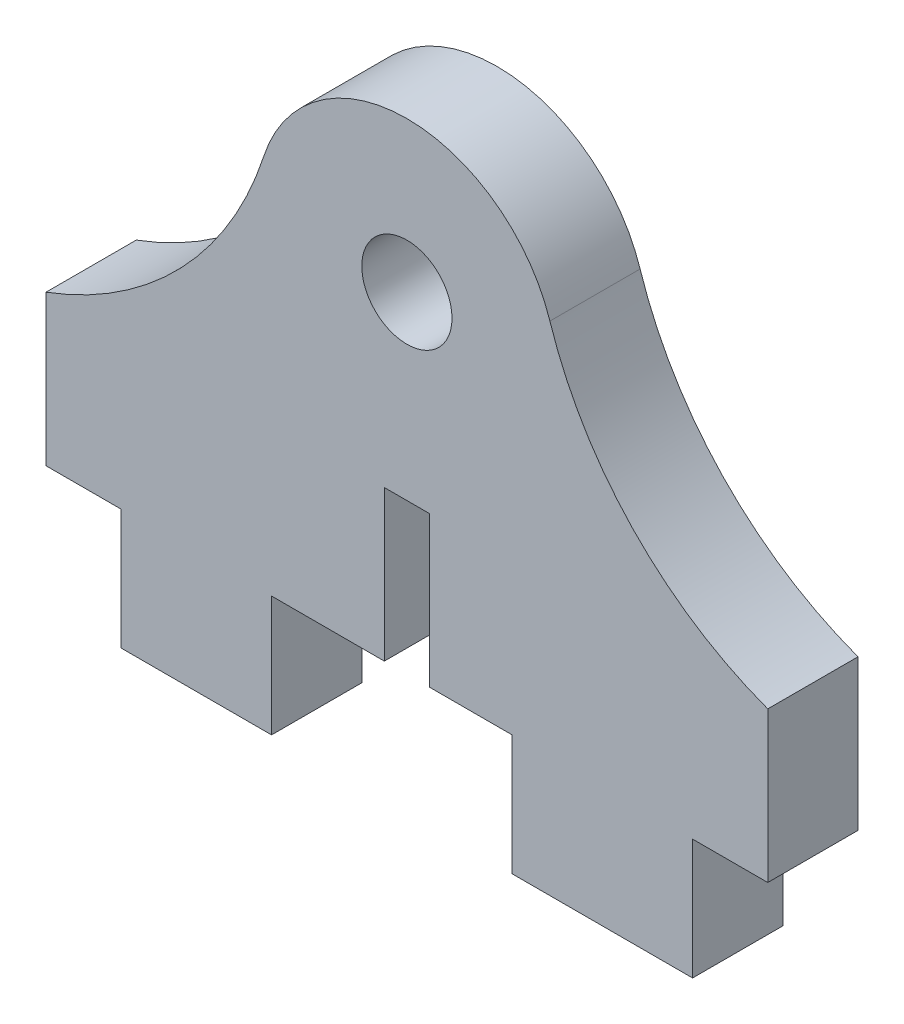
from build123d import *

# Parameters (mm, degrees)
SKETCH1_R           = 1.5
SKETCH1_R_2         = 1
BOSS_EXTRUDE1_DEPTH = 3
SKETCH2_W           = 21.215315346
SKETCH2_H           = 10.620784377
CUT_EXTRUDE1_DEPTH  = 4
SKETCH3_W           = 2.5
SKETCH3_H           = 4
CUT_EXTRUDE2_DEPTH  = 10
SKETCH4_W           = 2.5
SKETCH4_H           = 4
BOSS_EXTRUDE2_DEPTH = 3
SKETCH5_W           = 2.5
SKETCH5_H           = 5.5
BOSS_EXTRUDE3_DEPTH = 3
SKETCH6_W           = 1.5
SKETCH6_H           = 10
CUT_EXTRUDE3_DEPTH  = 5


with BuildPart() as part:
    # Sketch1 → Boss-Extrude1 (new body)
    with BuildSketch(Plane.XY):
        with BuildLine():
            Line((-1.25, -11), (-7, -11))
            Line((-7, -11), (-7, -15))
            Line((-7, -15), (-12, -15))
            Line((-12, -15), (-12, -11))
            Line((-12, -11), (-12, -6))
            ThreePointArc((-12, -6), (-7.512319363, -3.05842228), (-4.755323166, 1.544960058))
            ThreePointArc((-4.755323166, 1.544960058), (0, 5), (4.755323166, 1.544960058))
            ThreePointArc((4.755323166, 1.544960058), (7.512319363, -3.05842228), (12, -6))
            Line((12, -6), (12, -22.5))
            ThreePointArc((12, -22.5), (11.267766953, -24.267766953), (9.5, -25))
            Line((9.5, -25), (8.5, -25))
            ThreePointArc((8.5, -25), (6.732233047, -24.267766953), (6, -22.5))
            Line((6, -22.5), (6, -11))
            Line((6, -11), (1.25, -11))
            Line((1.25, -11), (1.25, -5.5))
            Line((1.25, -5.5), (-1.25, -5.5))
            Line((-1.25, -5.5), (-1.25, -11))
        make_face()
        Circle(SKETCH1_R, mode=Mode.SUBTRACT)
        with Locations((9, -22)):
            Circle(SKETCH1_R_2, mode=Mode.SUBTRACT)
    extrude(amount=BOSS_EXTRUDE1_DEPTH)

    # Sketch2 → Cut-Extrude1 (cut, through all)
    with BuildSketch(Plane.XY.offset(3)):
        with Locations((3.607657673, -20.310392189)):
            Rectangle(SKETCH2_W, SKETCH2_H)
    extrude(amount=-CUT_EXTRUDE1_DEPTH, mode=Mode.SUBTRACT)

    # Sketch3 → Cut-Extrude2 (cut)
    with BuildSketch(Plane.XY.offset(3)):
        with Locations((10.75, -13)):
            Rectangle(SKETCH3_W, SKETCH3_H)
        with Locations((-10.75, -13)):
            Rectangle(SKETCH3_W, SKETCH3_H)
    extrude(amount=-CUT_EXTRUDE2_DEPTH, mode=Mode.SUBTRACT)

    # Sketch4 → Boss-Extrude2 (add)
    with BuildSketch(Plane.XY.offset(3)):
        with Locations((-5.75, -13)):
            Rectangle(SKETCH4_W, SKETCH4_H)
        with Locations((4.75, -13)):
            Rectangle(SKETCH4_W, SKETCH4_H)
    extrude(amount=-BOSS_EXTRUDE2_DEPTH)

    # Sketch5 → Boss-Extrude3 (add)
    with BuildSketch(Plane(origin=(0, 0, 0), x_dir=(-1, 0, 0), z_dir=(0, 0, -1))):
        with Locations((0, -8.25)):
            Rectangle(SKETCH5_W, SKETCH5_H)
    extrude(amount=-BOSS_EXTRUDE3_DEPTH)

    # Sketch6 → Cut-Extrude3 (cut)
    with BuildSketch(Plane(origin=(0, 0, 0), x_dir=(-1, 0, 0), z_dir=(0, 0, -1))):
        with Locations((0, -11)):
            Rectangle(SKETCH6_W, SKETCH6_H)
    extrude(amount=-CUT_EXTRUDE3_DEPTH, mode=Mode.SUBTRACT)


solid = part.part
